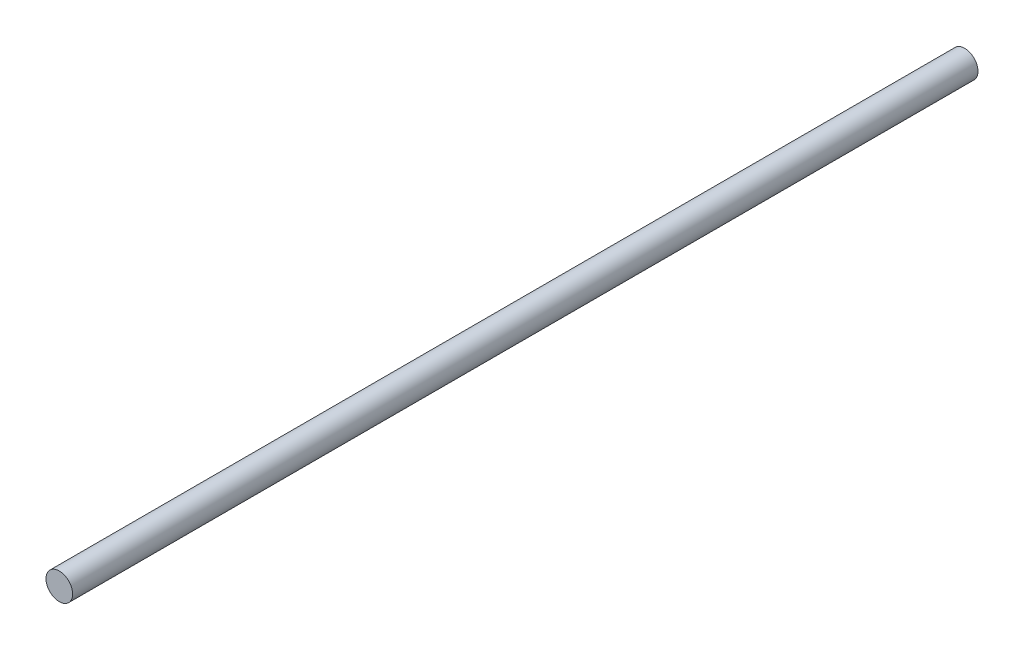
from build123d import *

# Parameters (mm, degrees)
SKETCH1_R           = 0.5
BOSS_EXTRUDE1_DEPTH = 34


with BuildPart() as part:
    # Sketch1 → Boss-Extrude1 (new body)
    with BuildSketch(Plane.XY):
        Circle(SKETCH1_R)
    extrude(amount=BOSS_EXTRUDE1_DEPTH)


solid = part.part
